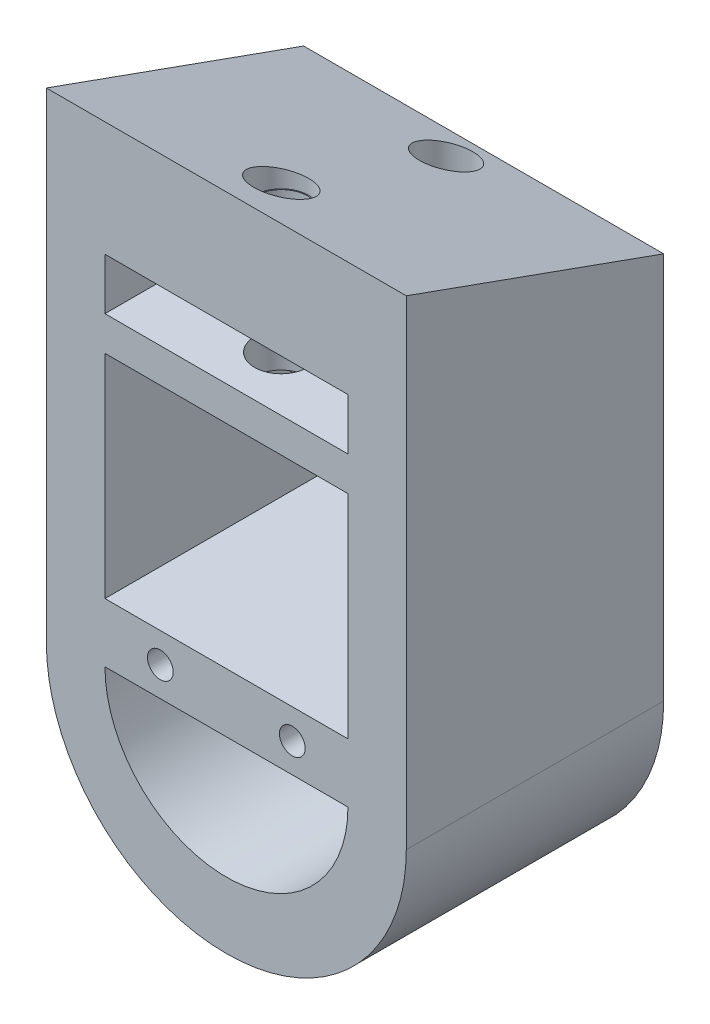
from build123d import *

# Parameters (mm, degrees)
SKETCH2_W                = 14.162138344
SKETCH2_H                = 3.4
SKETCH2_W_2              = 7.073181434
SKETCH2_H_2              = 3.44
SKETCH2_R                = 0.75
SKETCH2_W_3              = 7.08895691
BOSS_EXTRUDE1_DEPTH      = 20
BOSS_EXTRUDE2_START      = -11
BOSS_EXTRUDE2_DEPTH      = 23
CUT_EXTRUDE1_DEPTH       = 23
BOSS_EXTRUDE3_DEPTH      = 20
SKETCH8_R                = 1.6
CUT_EXTRUDE2_DEPTH       = 50
CUT_EXTRUDE3_START       = 9
SKETCH9_W                = 15
SKETCH9_H                = 3
CUT_EXTRUDE3_DEPTH       = 50
SKETCH10_W               = 8
SKETCH10_H               = 3.4
BOSS_EXTRUDE4_DEPTH      = 20
CUT_EXTRUDE4_DEPTH       = 15
CUT_EXTRUDE6_DEPTH       = 15
CUT_EXTRUDE7_DEPTH       = 14.77685015
CUT_EXTRUDE7_DEPTH_BACK  = 26.48895691
CUT_EXTRUDE8_DEPTH       = 11.48895691
CUT_EXTRUDE8_DEPTH_BACK  = 11.48895691
CUT_EXTRUDE9_DEPTH       = 11.48895691
CUT_EXTRUDE9_DEPTH_BACK  = 11.48895691
SKETCH16_W               = 14.162138344
SKETCH16_H               = 9.377104558
CUT_EXTRUDE10_DEPTH      = 16.0000001
CUT_EXTRUDE10_DEPTH_BACK = 15.024346574
BOSS_EXTRUDE5_DEPTH      = 15
SKETCH18_W               = 14.162138344
SKETCH18_H               = 2
BOSS_EXTRUDE6_DEPTH      = 15
SKETCH19_W               = 15
SKETCH19_H               = 3
BOSS_EXTRUDE7_DEPTH      = 15
CUT_EXTRUDE11_DEPTH      = 11.48895691
CUT_EXTRUDE11_DEPTH_BACK = 11.48895691
SKETCH21_R               = 1.55
CUT_EXTRUDE12_DEPTH      = 20
SKETCH23_W               = 14.162138344
SKETCH23_H               = 12.378444436
CUT_EXTRUDE13_DEPTH      = 16
CUT_EXTRUDE13_DEPTH_BACK = 15.024346574
SKETCH24_W               = 14.162138344
SKETCH24_H               = 2.5
BOSS_EXTRUDE8_DEPTH      = 5
CUT_EXTRUDE14_START      = -10
SKETCH25_R               = 1.55
CUT_EXTRUDE14_DEPTH      = 20


with BuildPart() as part:
    # Sketch2 → Boss-Extrude1 (new body)
    with BuildSketch(Plane.XY):
        with BuildLine():
            Line((-10.48895691, 0), (-10.48895691, -15))
            ThreePointArc((-10.48895691, -15), (0, -25.48895691), (10.48895691, -15))
            Line((10.48895691, -15), (10.48895691, 0))
            ThreePointArc((10.48895691, 0), (0, 10.48895691), (-10.48895691, 0))
        make_face()
        with BuildLine():
            ThreePointArc((-7.073181434, -14.546841059), (0.007887738, -21.627910231), (7.08895691, -14.546841059))
            Line((7.08895691, -14.546841059), (7.08895691, -0.433251968))
            ThreePointArc((7.08895691, -0.433251968), (0.007887738, 6.647817204), (-7.073181434, -0.433251968))
            Line((-7.073181434, -0.433251968), (-7.073181434, -14.546841059))
        make_face(mode=Mode.SUBTRACT)
        with Locations((0.007887738, -4.477329194)):
            Rectangle(SKETCH2_W, SKETCH2_H)
        with Locations((-3.536590717, -12.826841059)):
            Rectangle(SKETCH2_W_2, SKETCH2_H_2)
        with Locations((-3.845252141, -12.837457066)):
            Circle(SKETCH2_R, mode=Mode.SUBTRACT)
        with Locations((3.544478455, -12.826841059)):
            Rectangle(SKETCH2_W_3, SKETCH2_H_2)
        with Locations((3.845252141, -12.837457066)):
            Circle(SKETCH2_R, mode=Mode.SUBTRACT)
    extrude(amount=BOSS_EXTRUDE1_DEPTH)



with BuildPart() as body_2:
    # Sketch5 → Boss-Extrude2 (new body)
    with BuildSketch(Plane(origin=(0, 0, 0), x_dir=(0, 0, -1), z_dir=(1, 0, 0)).offset(BOSS_EXTRUDE2_START)):
        Polygon((-20, 10.48895691), (-20, 13.77685015), (0, 10.48895691), align=None)
    extrude(amount=BOSS_EXTRUDE2_DEPTH)

    # Sketch6 → Cut-Extrude1 (cut)
    with BuildSketch(Plane.XY):
        Polygon((-10.48895691, 0), (-10.48895691, 15.860273687), (-12.486191968, 15.860273687), (-12.486191968, -0.695838208), align=None)
        Polygon((10.48895691, 0), (10.48895691, 17.140856928), (14.451791198, 17.140856928), (14.085910272, 0), align=None)
    extrude(amount=CUT_EXTRUDE1_DEPTH, mode=Mode.SUBTRACT)


with BuildPart() as part_1:
    add(part.part)

    add(body_2.part)  # Boss-Extrude3 merges body 2
    # Sketch7 → Boss-Extrude3 (add)
    with BuildSketch(Plane.XY):
        Polygon((-10.48895691, 10.48895691), (-10.48895691, 0), (-4.00693271, 9.117877526), (3.3932631, 9.117877526), (10.48895691, 0), (10.48895691, 10.48895691), align=None)
    extrude(amount=BOSS_EXTRUDE3_DEPTH)

    # Sketch8 → Cut-Extrude2 (cut)
    with BuildSketch(Plane(origin=(0, 0, 0), x_dir=(1, 0, 0), z_dir=(0, 1, 0))):
        with Locations((0, -11.795956347)):
            Circle(SKETCH8_R)
    extrude(amount=CUT_EXTRUDE2_DEPTH, mode=Mode.SUBTRACT)

    # Sketch9 → Cut-Extrude3 (cut)
    with BuildSketch(Plane.XY.offset(CUT_EXTRUDE3_START)):
        with Locations((0, 8.87685015)):
            Rectangle(SKETCH9_W, SKETCH9_H)
    extrude(amount=CUT_EXTRUDE3_DEPTH, mode=Mode.SUBTRACT)

    # Sketch10 → Boss-Extrude4 (add)
    with BuildSketch(Plane.XY):
        with Locations((0, -4.477329194)):
            Rectangle(SKETCH10_W, SKETCH10_H)
    extrude(amount=-BOSS_EXTRUDE4_DEPTH)

    # Sketch11 → Cut-Extrude4 (cut)
    with BuildSketch(Plane(origin=(0, 0, 0), x_dir=(1, 0, 0), z_dir=(0, 1, 0))):
        with BuildLine():
            ThreePointArc((4, 27.93345462), (0, 23.93345462), (-4, 27.93345462))
            Line((-4, 27.93345462), (-5.669072563, 15.992564213))
            Line((-5.669072563, 15.992564213), (5.557395145, 15.474390906))
            Line((5.557395145, 15.474390906), (4, 27.93345462))
        make_face()
    extrude(amount=-CUT_EXTRUDE4_DEPTH, mode=Mode.SUBTRACT)

    # Sketch12 → Cut-Extrude6 (cut)
    with BuildSketch(Plane(origin=(0, 0, 0), x_dir=(1, 0, 0), z_dir=(0, 1, 0))):
        with BuildLine():
            ThreePointArc((-1.5, 10), (0, 8.5), (1.5, 10))
            ThreePointArc((1.5, 10), (1.499895352, 10.017718186), (1.499581421, 10.0354339))
            Line((1.499581421, 10.0354339), (-1.499581421, 10.0354339))
            ThreePointArc((-1.499581421, 10.0354339), (-1.499895352, 10.017718186), (-1.5, 10))
        make_face()
        with BuildLine():
            Line((-1.499581421, 10.0354339), (1.499581421, 10.0354339))
            ThreePointArc((1.499581421, 10.0354339), (0, 11.5), (-1.499581421, 10.0354339))
        make_face()
        with BuildLine():
            Line((-1.5, 0), (1.5, 0))
            Line((1.5, 0), (1.5, 10))
            ThreePointArc((1.5, 10), (0, 8.5), (-1.5, 10))
            Line((-1.5, 10), (-1.5, 0))
        make_face()
    extrude(amount=-CUT_EXTRUDE6_DEPTH, mode=Mode.SUBTRACT)

    # Sketch13 → Cut-Extrude7 (cut, two sides)
    with BuildSketch(Plane(origin=(0, 0, 0), x_dir=(1, 0, 0), z_dir=(0, 1, 0))) as cut_extrude7_sk:
        with BuildLine():
            Line((-7.439128098, 19.178498244), (-4, 10.024346574))
            ThreePointArc((-4, 10.024346574), (0, 14.024346574), (4, 10.024346574))
            Line((4, 10.024346574), (9.668085042, 17.513702334))
            Line((9.668085042, 17.513702334), (-7.439128098, 19.178498244))
        make_face()
    extrude(amount=CUT_EXTRUDE7_DEPTH, mode=Mode.SUBTRACT)
    extrude(cut_extrude7_sk.sketch, amount=-CUT_EXTRUDE7_DEPTH_BACK, mode=Mode.SUBTRACT)

    # Sketch14 → Cut-Extrude8 (cut, two sides)
    with BuildSketch(Plane(origin=(0, 0, 0), x_dir=(0, 0, -1), z_dir=(1, 0, 0))) as cut_extrude8_sk:
        Polygon((-26.730054166, 15.422520577), (-23.0368577, -28.4462079), (-15, -25.48895691), (-15, 13.72392169), align=None)
    extrude(amount=CUT_EXTRUDE8_DEPTH, mode=Mode.SUBTRACT)
    extrude(cut_extrude8_sk.sketch, amount=-CUT_EXTRUDE8_DEPTH_BACK, mode=Mode.SUBTRACT)

    # Sketch15 → Cut-Extrude9 (cut, two sides)
    with BuildSketch(Plane(origin=(0, 0, 0), x_dir=(0, 0, -1), z_dir=(1, 0, 0))) as cut_extrude9_sk:
        Polygon((-15, 12.95487684), (0, 7.573497647), (5.521522654, 8.824312447), (5.521522654, 13.501272135), (-15.144113177, 13.990721405), align=None)
    extrude(amount=CUT_EXTRUDE9_DEPTH, mode=Mode.SUBTRACT)
    extrude(cut_extrude9_sk.sketch, amount=-CUT_EXTRUDE9_DEPTH_BACK, mode=Mode.SUBTRACT)

    # Sketch16 → Cut-Extrude10 (cut, two sides)
    with BuildSketch(Plane.XY) as cut_extrude10_sk:
        with Locations((0.007887738, 1.911223085)):
            Rectangle(SKETCH16_W, SKETCH16_H)
    extrude(amount=CUT_EXTRUDE10_DEPTH, mode=Mode.SUBTRACT)
    extrude(cut_extrude10_sk.sketch, amount=-CUT_EXTRUDE10_DEPTH_BACK, mode=Mode.SUBTRACT)

    # Sketch17 → Boss-Extrude5 (add, through all)
    with BuildSketch(Plane.XY):
        Polygon((-7.073181434, 6.271603377), (7.08895691, 6.271603377), (7.08895691, 6.934816107), (-7.073181434, 6.934816107), (-7.073181434, 6.599775364), (-7.073181434, 6.43568937), align=None)
    extrude(amount=BOSS_EXTRUDE5_DEPTH)

    # Sketch18 → Boss-Extrude6 (add, through all)
    with BuildSketch(Plane.XY):
        with Locations((0.007887738, 2.271603377)):
            Rectangle(SKETCH18_W, SKETCH18_H)
    extrude(amount=BOSS_EXTRUDE6_DEPTH)

    # Sketch19 → Boss-Extrude7 (add)
    with BuildSketch(Plane.XY):
        with Locations((0, 8.87685015)):
            Rectangle(SKETCH19_W, SKETCH19_H)
    extrude(amount=BOSS_EXTRUDE7_DEPTH)

    # Sketch20 → Cut-Extrude11 (cut, two sides)
    with BuildSketch(Plane(origin=(0, 0, 0), x_dir=(0, 0, -1), z_dir=(1, 0, 0))) as cut_extrude11_sk:
        Polygon((-15, 12.95487684), (0, 7.573497647), (2.534300376, 12.95487684), align=None)
    extrude(amount=CUT_EXTRUDE11_DEPTH, mode=Mode.SUBTRACT)
    extrude(cut_extrude11_sk.sketch, amount=-CUT_EXTRUDE11_DEPTH_BACK, mode=Mode.SUBTRACT)

    # Sketch21 → Cut-Extrude12 (cut)
    with BuildSketch(Plane(origin=(0, 0, 0), x_dir=(1, 0, 0), z_dir=(0, 1, 0))):
        with Locations((0, -11.805650833)):
            Circle(SKETCH21_R)
    extrude(amount=CUT_EXTRUDE12_DEPTH, mode=Mode.SUBTRACT)

    # Sketch23 → Cut-Extrude13 (cut, two sides)
    with BuildSketch(Plane.XY) as cut_extrude13_sk:
        with Locations((0.007887738, -4.917618841)):
            Rectangle(SKETCH23_W, SKETCH23_H)
    extrude(amount=CUT_EXTRUDE13_DEPTH, mode=Mode.SUBTRACT)
    extrude(cut_extrude13_sk.sketch, amount=-CUT_EXTRUDE13_DEPTH_BACK, mode=Mode.SUBTRACT)

    # Sketch24 → Boss-Extrude8 (add)
    with BuildSketch(Plane.XY):
        with Locations((0.007887738, -2.978396623)):
            Rectangle(SKETCH24_W, SKETCH24_H)
    extrude(amount=BOSS_EXTRUDE8_DEPTH)

    # Sketch25 → Cut-Extrude14 (cut)
    with BuildSketch(Plane(origin=(0, 0, 0), x_dir=(1, 0, 0), z_dir=(0, 1, 0)).offset(CUT_EXTRUDE14_START)):
        with Locations((0, -2.191424263)):
            Circle(SKETCH25_R)
    extrude(amount=CUT_EXTRUDE14_DEPTH, mode=Mode.SUBTRACT)


solid = part_1.part
